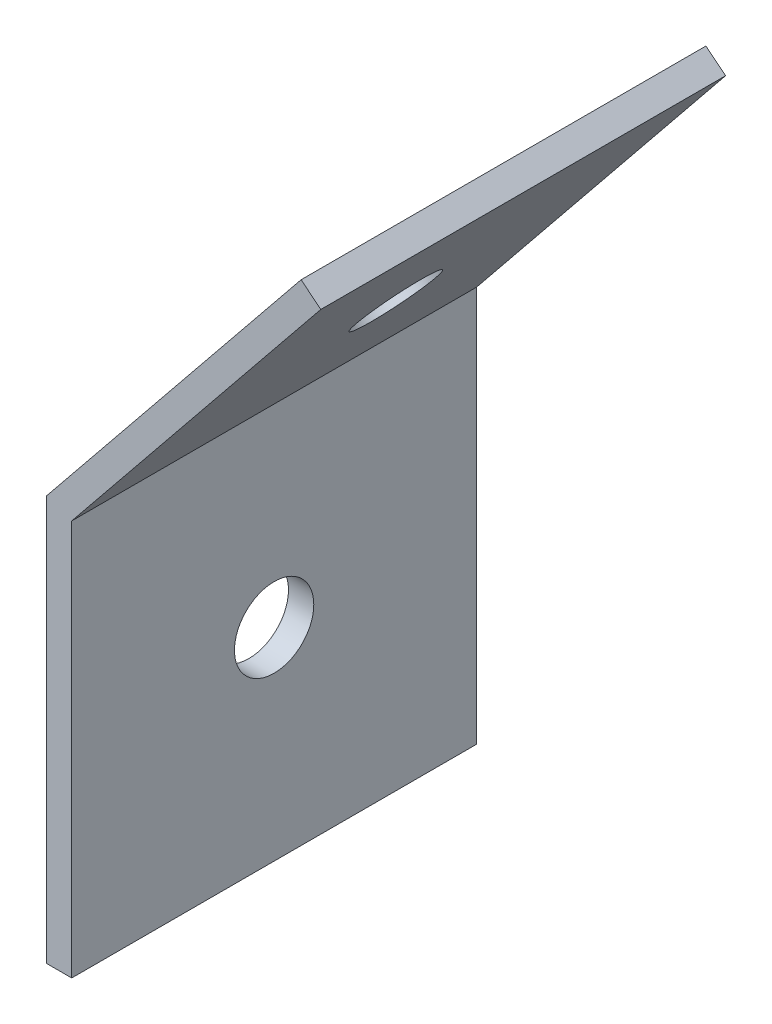
from build123d import *

# Parameters (mm, degrees)
EXTRUDE_THIN1_DEPTH            = 25.4
F_9_0_196_DIAMETER_HOLE1_D     = 4.9784
F_9_0_196_DIAMETER_HOLE1_DEPTH = 1.5885


with BuildPart() as part:
    # Sketch1 → Extrude-Thin1 (new body)
    with BuildSketch(Plane.XY):
        Polygon((0, -25.4), (0, 0), (15.981992956, 19.741729943), (17.215851078, 18.742855383), (1.5875, -0.562039024), (1.5875, -25.4), align=None)
    extrude(amount=-EXTRUDE_THIN1_DEPTH)

    # #9 (0.196) Diameter Hole1
    with Locations(Plane(origin=(1.233858121, -0.99887456, 0), x_dir=(0, 0, -1), z_dir=(0.777233462, -0.629212321, 0))):
        with Locations((12.7, 12.7)):
            f_9_0_196_diameter_hole1 = Hole(F_9_0_196_DIAMETER_HOLE1_D / 2, depth=F_9_0_196_DIAMETER_HOLE1_DEPTH)

    # Mirror1: #9 (0.196) Diameter Hole1 across plane
    add(f_9_0_196_diameter_hole1.mirror(Plane(origin=(0, 0, 0), x_dir=(0, 0, 1), z_dir=(-0.33374132, -0.942664697, 0))), mode=Mode.SUBTRACT)


solid = part.part
